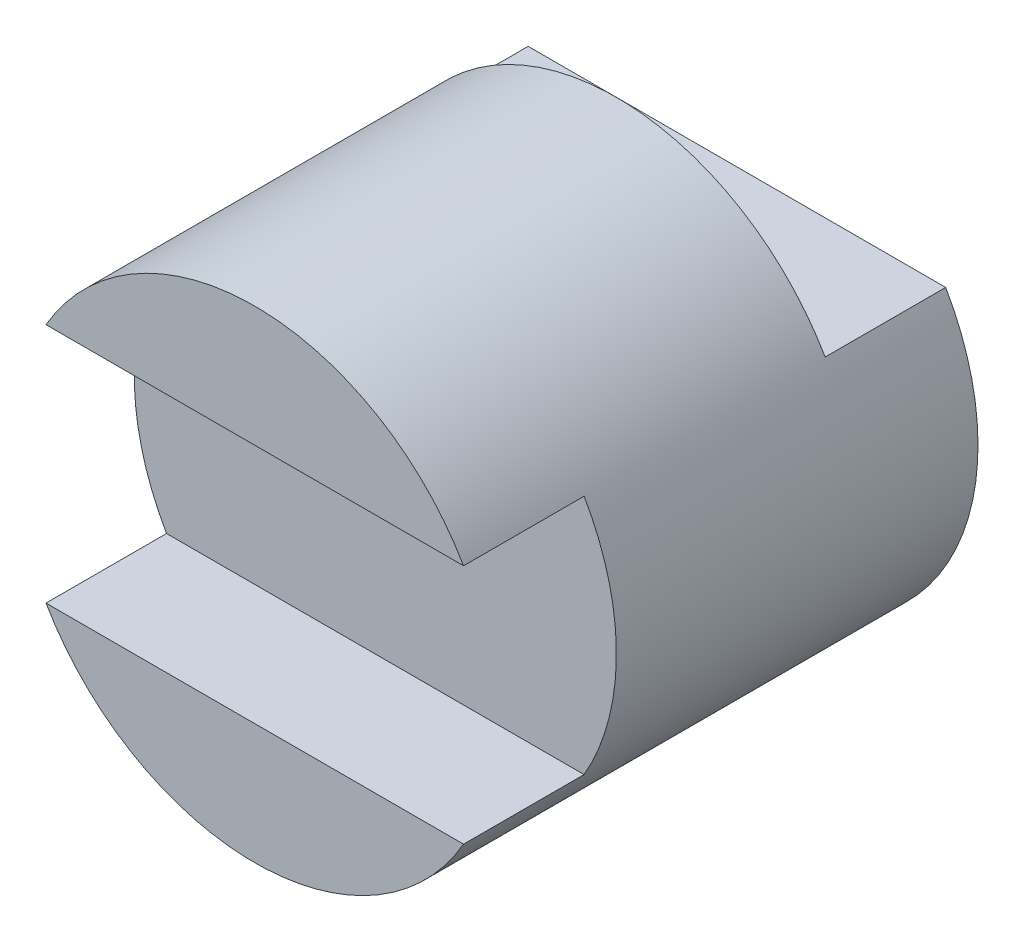
from build123d import *

# Parameters (mm, degrees)
SKETCH1_R           = 2
BOSS_EXTRUDE1_DEPTH = 3
BOSS_EXTRUDE2_DEPTH = 1
CUT_EXTRUDE1_DEPTH  = 1
BOSS_EXTRUDE3_DEPTH = 1


with BuildPart() as part:
    # Sketch1 → Boss-Extrude1 (new body)
    with BuildSketch(Plane.XY):
        Circle(SKETCH1_R)
    extrude(amount=BOSS_EXTRUDE1_DEPTH)

    # Sketch2 → Boss-Extrude2 (add)
    with BuildSketch(Plane.XY.offset(3)):
        with BuildLine():
            Line((-1.732050808, 1), (1.732050808, 1))
            ThreePointArc((1.732050808, 1), (0, 2), (-1.732050808, 1))
        make_face()
    extrude(amount=BOSS_EXTRUDE2_DEPTH)

    # Sketch3 → Cut-Extrude1 (cut)
    with BuildSketch(Plane(origin=(0, 0, 0), x_dir=(-1, 0, 0), z_dir=(0, 0, -1))):
        with BuildLine():
            Line((1.732050808, 1), (-1.732050808, 1))
            ThreePointArc((-1.732050808, 1), (0, 2), (1.732050808, 1))
        make_face()
    extrude(amount=-CUT_EXTRUDE1_DEPTH, mode=Mode.SUBTRACT)

    # Sketch4 → Boss-Extrude3 (add)
    with BuildSketch(Plane.XY.offset(3)):
        with BuildLine():
            Line((1.732050808, -1), (-1.732050808, -1))
            ThreePointArc((-1.732050808, -1), (0, -2), (1.732050808, -1))
        make_face()
    extrude(amount=BOSS_EXTRUDE3_DEPTH)


solid = part.part
